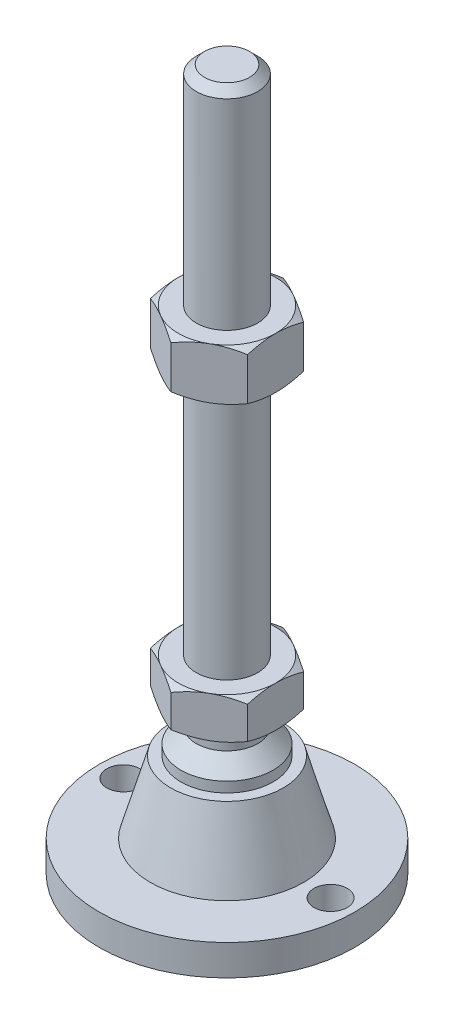
from build123d import *

# Parameters (mm, degrees)
EXTRUDE_1_DEPTH     = 8
EXTRUDE_2_DEPTH     = 10
SKETCH_5_R          = 3.25
CUT_EXTRUDE_1_DEPTH = 7


with BuildPart() as part:
    # Эскиз1 → Повернуть1 (revolve)
    with BuildSketch(Plane.XY, mode=Mode.PRIVATE) as revolve_1_sk:
        Polygon((0, 0), (-25, 0), (-25, 6), (-15, 6), (-11, 20), (-9, 20), (-9, 22), (-6, 25), (-6, 29), (-6, 37), (-6, 135.4), (-4.4, 137), (0, 137), align=None)
    revolve(revolve_1_sk.sketch.rotate(Axis((0, 0, 0), (0, 1, 0)), 180), axis=Axis((0, 0, 0), (0, 1, 0)))  # turned: the seam where the file's is

    # Эскиз2 → Бобышка-Вытянуть1 (add)
    with BuildSketch(Plane(origin=(0, 29, 0), x_dir=(1, 0, 0), z_dir=(0, 1, 0))):
        Polygon((0, 10.969655115), (-9.5, 5.484827557), (-9.5, -5.484827557), (0, -10.969655115), (9.5, -5.484827557), (9.5, 5.484827557), align=None)
    extrude(amount=EXTRUDE_1_DEPTH)

    # Эскиз3 → Бобышка-Вытянуть2 (add)
    with BuildSketch(Plane(origin=(0, 86.2, 0), x_dir=(1, 0, 0), z_dir=(0, 1, 0))):
        Polygon((9.5, 5.484827557), (0, 10.969655115), (-9.5, 5.484827557), (-9.5, -5.484827557), (0, -10.969655115), (9.5, -5.484827557), align=None)
    extrude(amount=EXTRUDE_2_DEPTH)

    # Эскиз4 → Вырез-Повернуть2 (revolve, cut)
    with BuildSketch(Plane.XY, mode=Mode.PRIVATE) as cut_revolve_2_sk:
        Polygon((-18.160254038, 96.2), (-9.5, 96.2), (-18.160254038, 91.2), align=None)
        Polygon((-18.160254038, 86.2), (-18.160254038, 91.2), (-9.5, 86.2), align=None)
        Polygon((-16.42820323, 37), (-16.42820323, 33), (-9.5, 37), align=None)
        Polygon((-16.42820323, 33), (-16.42820323, 29), (-9.5, 29), align=None)
    revolve(cut_revolve_2_sk.sketch.rotate(Axis((0, 137, 0), (0, -1, 0)), 180), axis=Axis((0, 137, 0), (0, -1, 0)), mode=Mode.SUBTRACT)  # turned: the seam where the file's is

    # Эскиз5 → Вырез-Вытянуть1 (cut, through all)
    with BuildSketch(Plane(origin=(0, 6, 0), x_dir=(1, 0, 0), z_dir=(0, 1, 0))):
        with Locations(Location((-20.25, 0, 0), (0, 0, 180))):  # turned: the seam where the file's is
            Circle(SKETCH_5_R)
        with Locations(Location((20.25, 0, 0), (0, 0, 180))):  # turned: the seam where the file's is
            Circle(SKETCH_5_R)
    extrude(amount=-CUT_EXTRUDE_1_DEPTH, mode=Mode.SUBTRACT)


solid = part.part
